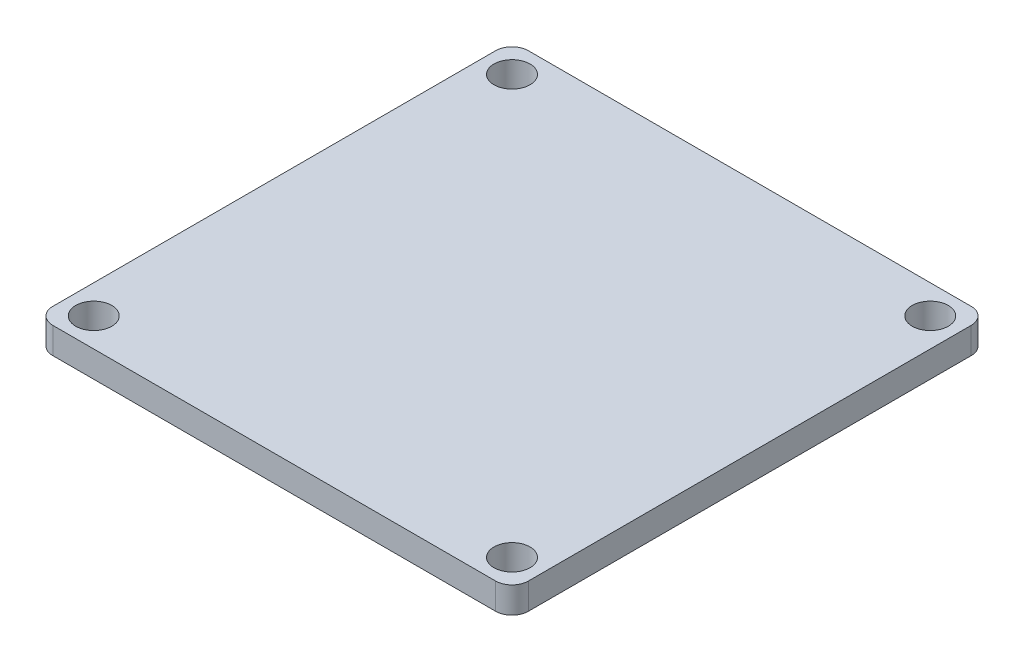
from build123d import *

# Parameters (mm, degrees)
SKIZZE1_W                       = 29
SKIZZE1_H                       = 29
SKIZZE1_R                       = 1.1
AUFSATZ_LINEAR_AUSTRAGEN1_DEPTH = 1.6
VERRUNDUNG1_R                   = 1


with BuildPart() as part:
    # Skizze1 → Aufsatz-Linear austragen1 (new body)
    with BuildSketch(Plane(origin=(0, 0, 0), x_dir=(1, 0, 0), z_dir=(0, 1, 0))):
        Rectangle(SKIZZE1_W, SKIZZE1_H)
        with Locations((-12.75, 12.75)):
            Circle(SKIZZE1_R, mode=Mode.SUBTRACT)
        with Locations((12.75, 12.75)):
            Circle(SKIZZE1_R, mode=Mode.SUBTRACT)
        with Locations((12.75, -12.75)):
            Circle(SKIZZE1_R, mode=Mode.SUBTRACT)
        with Locations((-12.75, -12.75)):
            Circle(SKIZZE1_R, mode=Mode.SUBTRACT)
    extrude(amount=AUFSATZ_LINEAR_AUSTRAGEN1_DEPTH)

    # Verrundung1
    verrundung1_edges = [part.edges().sort_by_distance(p)[0] for p in [
        (14.5, 0.8, 14.5),
        (-14.5, 0.8, 14.5),
        (-14.5, 0.8, -14.5),
        (14.5, 0.8, -14.5),
    ]]
    fillet(verrundung1_edges, radius=VERRUNDUNG1_R)


solid = part.part
